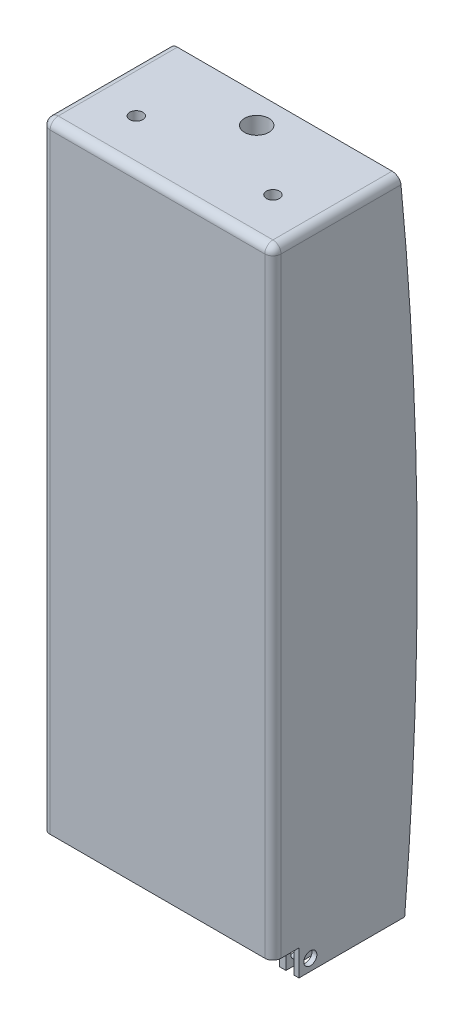
from build123d import *

# Parameters (mm, degrees)
CUT_EXTRUDE1_DEPTH      = 10
CUT_EXTRUDE1_DEPTH_BACK = 10
SKETCH7_W               = 161.67088451347962
SKETCH7_H               = 99.40268669666085
SKETCH8_W               = 4.999999999999993
SKETCH8_H               = 94
CUT_EXTRUDE2_DEPTH      = 35
SKETCH9_R               = 7.5
SKETCH9_R_2             = 4.000000000000013
SKETCH9_R_3             = 4.000000000000005
CUT_EXTRUDE3_DEPTH      = 405.82341829494015
SKETCH10_R              = 4.000000000000005
CUT_EXTRUDE4_DEPTH      = 433.4638713233743
SKETCH11_W              = 141.9999999999999
SKETCH11_H              = 16
BOSS_EXTRUDE1_DEPTH     = 380
FILLET2_R               = 5
FILLET3_R               = 5
FILLET4_R               = 5
FILLET5_R               = 5
FILLET6_R               = 5
CUT_EXTRUDE5_DEPTH      = 435.42030339292387


with BuildPart() as part:
    # Sweep2: sweep along a path in Sketch4
    with BuildLine(Plane.XY) as sweep2_path:
        Line((-65, 400), (-64.99999999999994, 10.000000000000007))
        ThreePointArc((-64.99999999999994, 10.000000000000007), (-62.07106781186544, 2.928932188134527), (-54.99999999999996, 0))
        Line((-54.99999999999996, 0), (54.99999999999999, 0))
        ThreePointArc((54.99999999999999, 0), (62.071067811865476, 2.9289321881345227), (65, 10))
        Line((65, 10), (65, 400))
        Line((65, 400), (-65, 400))
    # Sketch6 → Sweep2 (sweep)
    with BuildSketch(Plane(origin=(0, 0, 0), x_dir=(0, 0, -1), z_dir=(1, 0, 0))):
        Polygon((44.99999999999967, 406), (-45.00000000000032, 406), (-45.00000000000032, 393.99999999999994), (44.99999999999968, 394), align=None)
    sweep(path=sweep2_path.line, transition=Transition.RIGHT)

    # Sketch7 → Cut-Extrude1 (cut, two sides: drawn at the far end of the back side and taken through both)
    with BuildSketch(Plane(origin=(0, 0, 0), x_dir=(1, 0, 0), z_dir=(0, 1, 0)).offset(-CUT_EXTRUDE1_DEPTH_BACK)):
        Rectangle(SKETCH7_W, SKETCH7_H)
    extrude(amount=CUT_EXTRUDE1_DEPTH + CUT_EXTRUDE1_DEPTH_BACK, mode=Mode.SUBTRACT)

    # Sketch8 → Cut-Extrude2 (cut)
    with BuildSketch(Plane(origin=(0, 0, 0), x_dir=(1, 0, 0), z_dir=(0, 1, 0))):
        with Locations((-65.5, 0.24224418482823395)):
            Rectangle(SKETCH8_W, SKETCH8_H)
        with Locations((65.5, 0.24224418482823395)):
            Rectangle(SKETCH8_W, SKETCH8_H)
    extrude(amount=CUT_EXTRUDE2_DEPTH, mode=Mode.SUBTRACT)

    # Sketch9 → Cut-Extrude3 (cut, through all)
    with BuildSketch(Plane(origin=(0, 406, 0), x_dir=(1, 0, 0), z_dir=(0, 1, 0))):
        with Locations(Location((0, 0, 0), (0, 0, 270))):
            Circle(SKETCH9_R)
        with Locations(Location((-42, 31.999999999999993, 0), (0, 0, 270))):
            Circle(SKETCH9_R_2)
        with Locations(Location((-42, -32.00000000000001, 0), (0, 0, 270))):
            Circle(SKETCH9_R_3)
        with Locations(Location((42, -31.999999999999954, 0), (0, 0, 90))):
            Circle(SKETCH9_R_3)
        with Locations(Location((42, 32, 0), (0, 0, 90))):
            Circle(SKETCH9_R_2)
    extrude(amount=-CUT_EXTRUDE3_DEPTH, mode=Mode.SUBTRACT)

    # Sketch10 → Cut-Extrude4 (cut, through all)
    with BuildSketch(Plane(origin=(70.99999999999996, 0, 0), x_dir=(0, 0, -1), z_dir=(1, 0, 0))):
        with Locations((-37.999999999999936, 17.000000000000014)):
            Circle(SKETCH10_R)
    extrude(amount=-CUT_EXTRUDE4_DEPTH, mode=Mode.SUBTRACT)

    # Sketch11 → Boss-Extrude1 (add)
    with BuildSketch(Plane(origin=(0, 406, 0), x_dir=(1, 0, 0), z_dir=(0, 1, 0))):
        with Locations((0, -52.999999999999936)):
            Rectangle(SKETCH11_W, SKETCH11_H)
    extrude(amount=-BOSS_EXTRUDE1_DEPTH)

    # Fillet2
    fillet2_edges = [part.edges().sort_by_distance(p)[0] for p in [
        (59.00000000000001, 202, -44.99999999999968),
    ]]
    fillet(fillet2_edges, radius=FILLET2_R)

    # Fillet3
    fillet3_edges = [part.edges().sort_by_distance(p)[0] for p in [
        (71, 208, -44.99999999999967),
    ]]
    fillet(fillet3_edges, radius=FILLET3_R)

    # Fillet4
    fillet4_edges = [part.edges().sort_by_distance(p)[0] for p in [
        (-59.00000000000001, 202, -44.99999999999968),
    ]]
    fillet(fillet4_edges, radius=FILLET4_R)

    # Fillet5
    fillet5_edges = [part.edges().sort_by_distance(p)[0] for p in [
        (-71, 208, -44.99999999999967),
    ]]
    fillet(fillet5_edges, radius=FILLET5_R)

    # Fillet6
    fillet6_edges = [part.edges().sort_by_distance(p)[0] for p in [
        (70.99999999999994, 216, 60.999999999999936),
        (-70.99999999999994, 216, 60.999999999999936),
        (0, 406, 60.999999999999936),
        (0, 406, -44.99999999999967),
        (0, 406, -44.99999999999967),
        (70.99999999999997, 406, 10.500000000000085),
        (-70.99999999999997, 406, 10.500000000000135),
        (69.53553390593274, 406, -43.53553390593251),
        (-69.53553390593274, 406, -43.53553390593241),
    ]]
    fillet(fillet6_edges, radius=FILLET6_R)

    # Sketch12 → Cut-Extrude5 (cut, through all)
    with BuildSketch(Plane.ZY.offset(70.9999999999999)):
        with BuildLine():
            Line((-19.99811023879916, 9.999999999999995), (-79.77303285275339, 10.000000000000018))
            Line((-79.77303285275339, 10.000000000000018), (-79.77303285275339, 406.4421165391139))
            Line((-79.77303285275339, 406.4421165391139), (-17.24924979661946, 406))
            ThreePointArc((-17.24924979661946, 406), (-27.67595887590869, 208.0628369981441), (-19.99811023879916, 9.999999999999995))
        make_face()
    extrude(amount=-CUT_EXTRUDE5_DEPTH, mode=Mode.SUBTRACT)


solid = part.part
